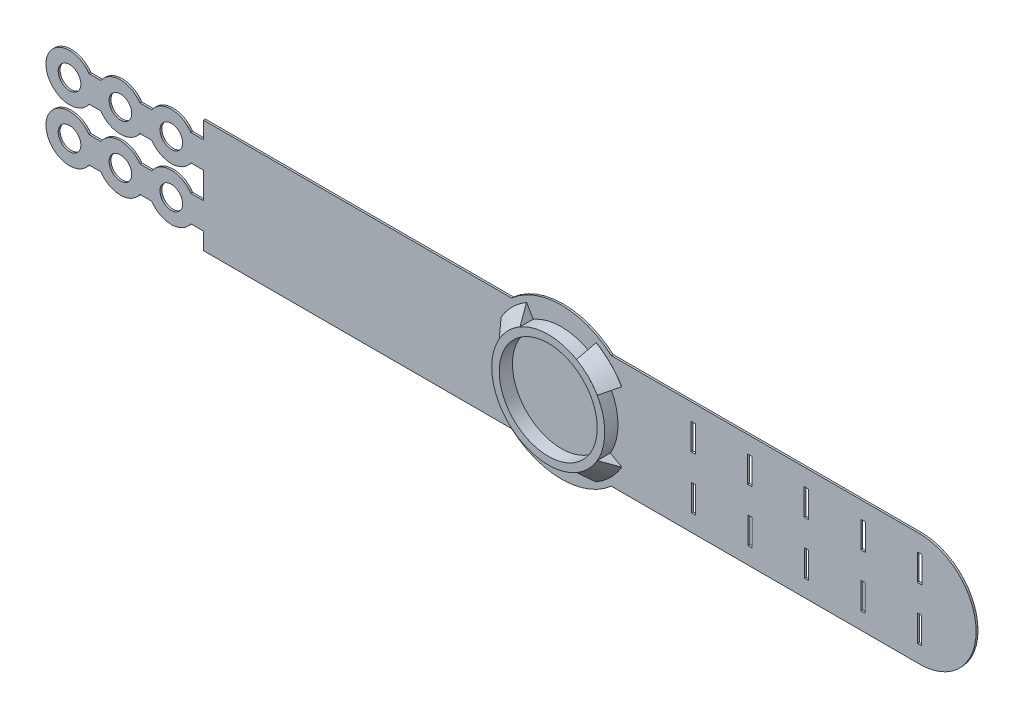
from build123d import *

# Parameters (mm, degrees)
SKETCH_1_R        = 3
SKETCH_1_W        = 1
SKETCH_1_H        = 7
SKETCH_1_W_2      = 1.2
EXTRUDE_2_DEPTH   = 0.5
SKETCH_3_R        = 15
SKETCH_3_R_2      = 13
EXTRUDE_3_DEPTH   = 4
EXTRUDE_4_DEPTH   = 3.5
EXTRUDE_4_2_DEPTH = 3.5
EXTRUDE_4_3_DEPTH = 3.5
EXTRUDE_4_4_DEPTH = 3.5


with BuildPart() as part:
    # Эскиз1 → Бобышка-Вытянуть2 (new body)
    with BuildSketch(Plane.XY):
        with BuildLine():
            Line((95, 15), (13.228756555, 15))
            ThreePointArc((13.228756555, 15), (0, 20), (-13.228756555, 15))
            Line((-13.228756555, 15), (-95, 15))
            Line((-95, 15), (-95, 10.5))
            Line((-95, 10.5), (-98.321921206, 10.5))
            ThreePointArc((-98.321921206, 10.5), (-103.5, 13.25), (-108.678078794, 10.5))
            Line((-108.678078794, 10.5), (-111.821921206, 10.5))
            ThreePointArc((-111.821921206, 10.5), (-117, 13.25), (-122.178078794, 10.5))
            Line((-122.178078794, 10.5), (-125.321921206, 10.5))
            ThreePointArc((-125.321921206, 10.5), (-136.75, 7), (-125.321921206, 3.5))
            Line((-125.321921206, 3.5), (-122.178078794, 3.5))
            ThreePointArc((-122.178078794, 3.5), (-117, 0.75), (-111.821921206, 3.5))
            Line((-111.821921206, 3.5), (-108.678078794, 3.5))
            ThreePointArc((-108.678078794, 3.5), (-103.5, 0.75), (-98.321921206, 3.5))
            Line((-98.321921206, 3.5), (-95, 3.5))
            Line((-95, 3.5), (-95, -3.5))
            Line((-95, -3.5), (-98.321921206, -3.5))
            ThreePointArc((-98.321921206, -3.5), (-103.5, -0.75), (-108.678078794, -3.5))
            Line((-108.678078794, -3.5), (-111.821921206, -3.5))
            ThreePointArc((-111.821921206, -3.5), (-117, -0.75), (-122.178078794, -3.5))
            Line((-122.178078794, -3.5), (-125.321921206, -3.5))
            ThreePointArc((-125.321921206, -3.5), (-136.75, -7), (-125.321921206, -10.5))
            Line((-125.321921206, -10.5), (-122.178078794, -10.5))
            ThreePointArc((-122.178078794, -10.5), (-117, -13.25), (-111.821921206, -10.5))
            Line((-111.821921206, -10.5), (-108.678078794, -10.5))
            ThreePointArc((-108.678078794, -10.5), (-103.5, -13.25), (-98.321921206, -10.5))
            Line((-98.321921206, -10.5), (-95, -10.5))
            Line((-95, -10.5), (-95, -15))
            Line((-95, -15), (-13.228756555, -15))
            ThreePointArc((-13.228756555, -15), (0, -20), (13.228756555, -15))
            Line((13.228756555, -15), (95, -15))
            ThreePointArc((95, -15), (110, 0), (95, 15))
        make_face()
        with Locations((-130.5, -7)):
            Circle(SKETCH_1_R, mode=Mode.SUBTRACT)
        with Locations((-117, -7)):
            Circle(SKETCH_1_R, mode=Mode.SUBTRACT)
        with Locations((-103.5, -7)):
            Circle(SKETCH_1_R, mode=Mode.SUBTRACT)
        with Locations((35, -7)):
            Rectangle(SKETCH_1_W, SKETCH_1_H, mode=Mode.SUBTRACT)
        with Locations((50, -7)):
            Rectangle(SKETCH_1_W, SKETCH_1_H, mode=Mode.SUBTRACT)
        with Locations((65, -7)):
            Rectangle(SKETCH_1_W, SKETCH_1_H, mode=Mode.SUBTRACT)
        with Locations((80, -7)):
            Rectangle(SKETCH_1_W, SKETCH_1_H, mode=Mode.SUBTRACT)
        with Locations((95, -7)):
            Rectangle(SKETCH_1_W, SKETCH_1_H, mode=Mode.SUBTRACT)
        with Locations((-130.5, 7)):
            Circle(SKETCH_1_R, mode=Mode.SUBTRACT)
        with Locations((-117, 7)):
            Circle(SKETCH_1_R, mode=Mode.SUBTRACT)
        with Locations((-103.5, 7)):
            Circle(SKETCH_1_R, mode=Mode.SUBTRACT)
        with Locations((35, 7)):
            Rectangle(SKETCH_1_W_2, SKETCH_1_H, mode=Mode.SUBTRACT)
        with Locations((50, 7)):
            Rectangle(SKETCH_1_W_2, SKETCH_1_H, mode=Mode.SUBTRACT)
        with Locations((65, 7)):
            Rectangle(SKETCH_1_W_2, SKETCH_1_H, mode=Mode.SUBTRACT)
        with Locations((80, 7)):
            Rectangle(SKETCH_1_W_2, SKETCH_1_H, mode=Mode.SUBTRACT)
        with Locations((95, 7)):
            Rectangle(SKETCH_1_W_2, SKETCH_1_H, mode=Mode.SUBTRACT)
    extrude(amount=EXTRUDE_2_DEPTH)

    # Эскиз3 → Бобышка-Вытянуть3 (add)
    with BuildSketch(Plane(origin=(0, 0, 0), x_dir=(-1, 0, 0), z_dir=(0, 0, -1))):
        Circle(SKETCH_3_R)
        Circle(SKETCH_3_R_2, mode=Mode.SUBTRACT)
    extrude(amount=-EXTRUDE_3_DEPTH)


with BuildPart() as body_2:
    # Эскиз8 → Бобышка-Вытянуть4 (new body)
    with BuildSketch(Plane.XY.offset(0.5)):
        with BuildLine():
            Line((12.990381057, 7.5), (15.988424537, 9.23092121))
            ThreePointArc((15.988424537, 9.23092121), (13.054493969, 13.054493969), (9.23092121, 15.988424537))
            Line((9.23092121, 15.988424537), (7.5, 12.990381057))
            ThreePointArc((7.5, 12.990381057), (10.606601718, 10.606601718), (12.990381057, 7.5))
        make_face()
    extrude(amount=EXTRUDE_4_DEPTH)


with BuildPart() as body_3:
    # Эскиз8 → Extrude 4 2 (new body)
    with BuildSketch(Plane.XY.offset(0.5)):
        with BuildLine():
            ThreePointArc((7.5, -12.990381057), (10.606601718, -10.606601718), (12.990381057, -7.5))
            Line((12.990381057, -7.5), (15.988424537, -9.23092121))
            ThreePointArc((15.988424537, -9.23092121), (13.054493969, -13.054493969), (9.23092121, -15.988424537))
            Line((9.23092121, -15.988424537), (7.5, -12.990381057))
        make_face()
    extrude(amount=EXTRUDE_4_2_DEPTH)


with BuildPart() as body_4:
    # Эскиз8 → Extrude 4 3 (new body)
    with BuildSketch(Plane.XY.offset(0.5)):
        with BuildLine():
            ThreePointArc((-12.990381057, -7.5), (-10.606601718, -10.606601718), (-7.5, -12.990381057))
            Line((-7.5, -12.990381057), (-9.23092121, -15.988424537))
            ThreePointArc((-9.23092121, -15.988424537), (-13.054493969, -13.054493969), (-15.988424537, -9.23092121))
            Line((-15.988424537, -9.23092121), (-12.990381057, -7.5))
        make_face()
    extrude(amount=EXTRUDE_4_3_DEPTH)


with BuildPart() as body_5:
    # Эскиз8 → Extrude 4 4 (new body)
    with BuildSketch(Plane.XY.offset(0.5)):
        with BuildLine():
            ThreePointArc((-7.5, 12.990381057), (-10.606601718, 10.606601718), (-12.990381057, 7.5))
            Line((-12.990381057, 7.5), (-15.988424537, 9.23092121))
            ThreePointArc((-15.988424537, 9.23092121), (-13.054493969, 13.054493969), (-9.23092121, 15.988424537))
            Line((-9.23092121, 15.988424537), (-7.5, 12.990381057))
        make_face()
    extrude(amount=EXTRUDE_4_4_DEPTH)


with BuildPart() as sweep_1_tool:
    # Вырез-По траектории1: sweep along a curve in space
    with BuildLine() as sweep_1_path:
        ThreePointArc((-13, 0, 4), (-9.192388155, 9.192388155, 4), (0, 13, 4))
        ThreePointArc((0, 13, 4), (9.192388155, 9.192388155, 4), (13, 0, 4))
        ThreePointArc((13, 0, 4), (9.192388155, -9.192388155, 4), (0, -13, 4))
        ThreePointArc((0, -13, 4), (-9.192388155, -9.192388155, 4), (-13, 0, 4))
    # Sketch 2 → Вырез-По траектории1 (sweep)
    with BuildSketch(Plane(origin=(17.656340523, 5.523009727, 0.5), x_dir=(-0.6752443953624955, -0.2098714313406492, 0.7071060661870786), z_dir=(-0.29872202469959164, 0.9543380466699508, -0.0020111284293495265))):
        Polygon((0, 0), (4.949752473, 0), (2.474881242, 2.474876237), align=None)
    sweep(path=sweep_1_path.line)


with BuildPart() as body_2_1:
    add(body_2.part)

    # Вырез-По траектории1: cut by sweep_1_tool
    add(sweep_1_tool.part, mode=Mode.SUBTRACT)


with BuildPart() as body_3_1:
    add(body_3.part)

    # Вырез-По траектории1: cut by sweep_1_tool
    add(sweep_1_tool.part, mode=Mode.SUBTRACT)


with BuildPart() as body_4_1:
    add(body_4.part)

    # Вырез-По траектории1: cut by sweep_1_tool
    add(sweep_1_tool.part, mode=Mode.SUBTRACT)


with BuildPart() as body_5_1:
    add(body_5.part)

    # Вырез-По траектории1: cut by sweep_1_tool
    add(sweep_1_tool.part, mode=Mode.SUBTRACT)


solid = Compound([part.part, body_2_1.part, body_3_1.part, body_4_1.part, body_5_1.part])
